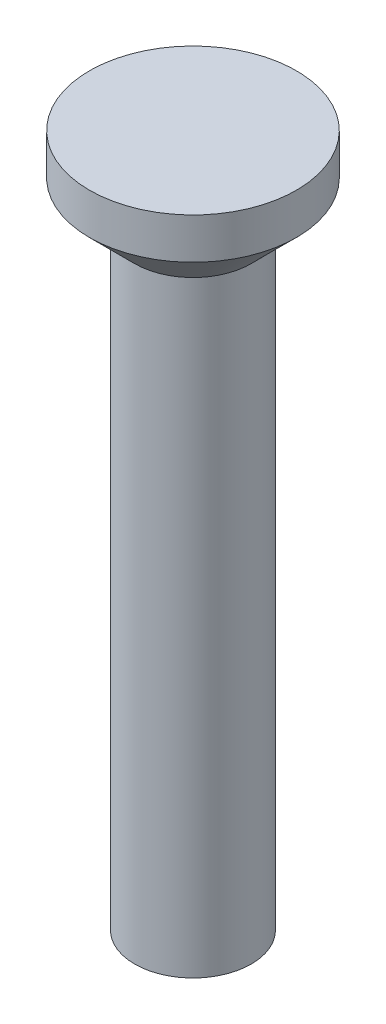
from build123d import *


with BuildPart() as part:
    # Эскиз1 → Повернуть1 (revolve)
    with BuildSketch(Plane.XY):
        Polygon((0, 0), (25, 0), (25, 260), (44.353980996, 279.353980996), (44.353980996, 296.924237963), (0, 296.924237963), align=None)
    revolve(axis=Axis((0, 348.080420571, 0), (0, -1, 0)))


solid = part.part
